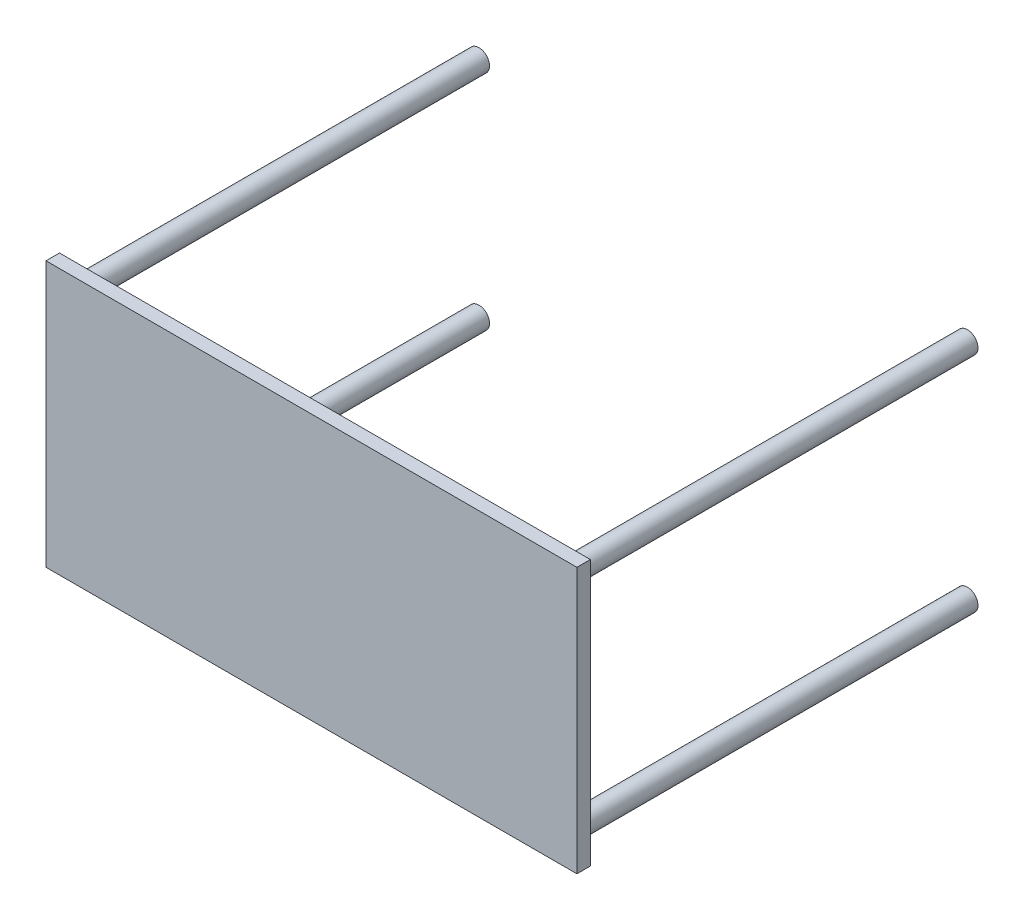
from build123d import *

# Parameters (mm, degrees)
SKETCH1_W           = 1000
SKETCH1_H           = 500
BOSS_EXTRUDE1_DEPTH = 25.4
SKETCH2_R           = 20
BOSS_EXTRUDE2_DEPTH = 750


with BuildPart() as part:
    # Sketch1 → Boss-Extrude1 (new body)
    with BuildSketch(Plane.XY):
        Rectangle(SKETCH1_W, SKETCH1_H)
    extrude(amount=BOSS_EXTRUDE1_DEPTH)

    # Sketch2 → Boss-Extrude2 (add)
    with BuildSketch(Plane.XY):
        with Locations((460, 210)):
            Circle(SKETCH2_R)
        with Locations((460, -210)):
            Circle(SKETCH2_R)
        with Locations((-460, -210)):
            Circle(SKETCH2_R)
        with Locations((-460, 210)):
            Circle(SKETCH2_R)
    extrude(amount=-BOSS_EXTRUDE2_DEPTH)


solid = part.part
